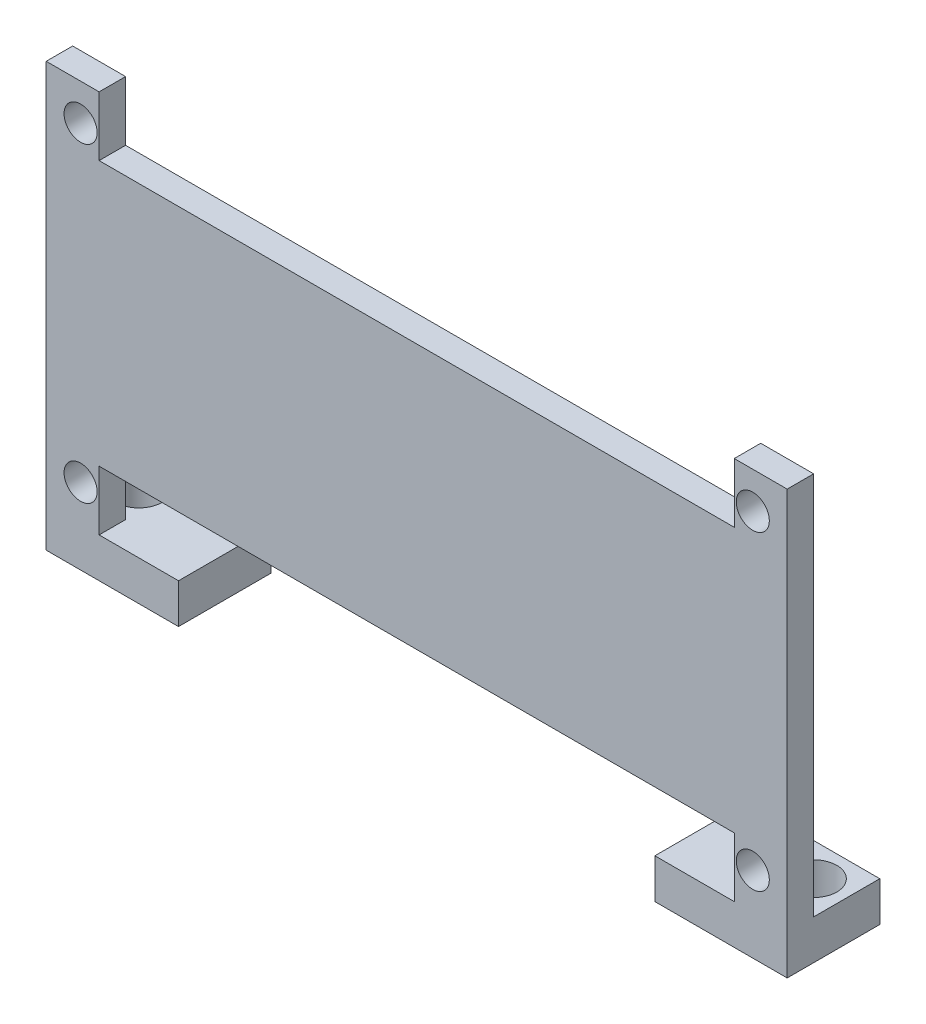
from build123d import *

# Parameters (mm, degrees)
ESBO_O1_R                = 1.25
RESSALTO_EXTRUS_O1_DEPTH = 2
ESBO_O3_W                = 10
ESBO_O3_H                = 3
RESSALTO_EXTRUS_O2_DEPTH = 7
ESBO_O4_R                = 1.75
CORTE_EXTRUS_O1_DEPTH    = 5


with BuildPart() as part:
    # Esboço1 → Ressalto-extrusão1 (new body)
    with BuildSketch(Plane.XY):
        Polygon((-9.965681545, 17.117604611), (-13.965681545, 17.117604611), (-13.965681545, -11.882395389), (-9.965681545, -11.882395389), (-9.965681545, -7.382395389), (38.034318455, -7.382395389), (38.034318455, -11.882395389), (42.034318455, -11.882395389), (42.034318455, 17.117604611), (38.034318455, 17.117604611), (38.034318455, 12.617604611), (-9.965681545, 12.617604611), align=None)
        with Locations((-11.365681545, -9.132395389)):
            Circle(ESBO_O1_R, mode=Mode.SUBTRACT)
        with Locations((39.434318455, -9.132395389)):
            Circle(ESBO_O1_R, mode=Mode.SUBTRACT)
        with Locations((-11.365681545, 14.367604611)):
            Circle(ESBO_O1_R, mode=Mode.SUBTRACT)
        with Locations((39.434318455, 14.367604611)):
            Circle(ESBO_O1_R, mode=Mode.SUBTRACT)
    extrude(amount=RESSALTO_EXTRUS_O1_DEPTH)

    # Esboço3 → Ressalto-extrusão2 (add)
    with BuildSketch(Plane.XY.offset(2)):
        with Locations((-8.965681545, -13.382395389)):
            Rectangle(ESBO_O3_W, ESBO_O3_H)
        with Locations((37.034318455, -13.382395389)):
            Rectangle(ESBO_O3_W, ESBO_O3_H)
    extrude(amount=-RESSALTO_EXTRUS_O2_DEPTH)

    # Esboço4 → Corte-extrusão1 (cut)
    with BuildSketch(Plane(origin=(0, -11.882395389, 0), x_dir=(1, 0, 0), z_dir=(0, 1, 0))):
        with Locations((-11.465681545, 2.5)):
            Circle(ESBO_O4_R)
        with Locations((39.534318455, 2.5)):
            Circle(ESBO_O4_R)
    extrude(amount=-CORTE_EXTRUS_O1_DEPTH, mode=Mode.SUBTRACT)


solid = part.part
